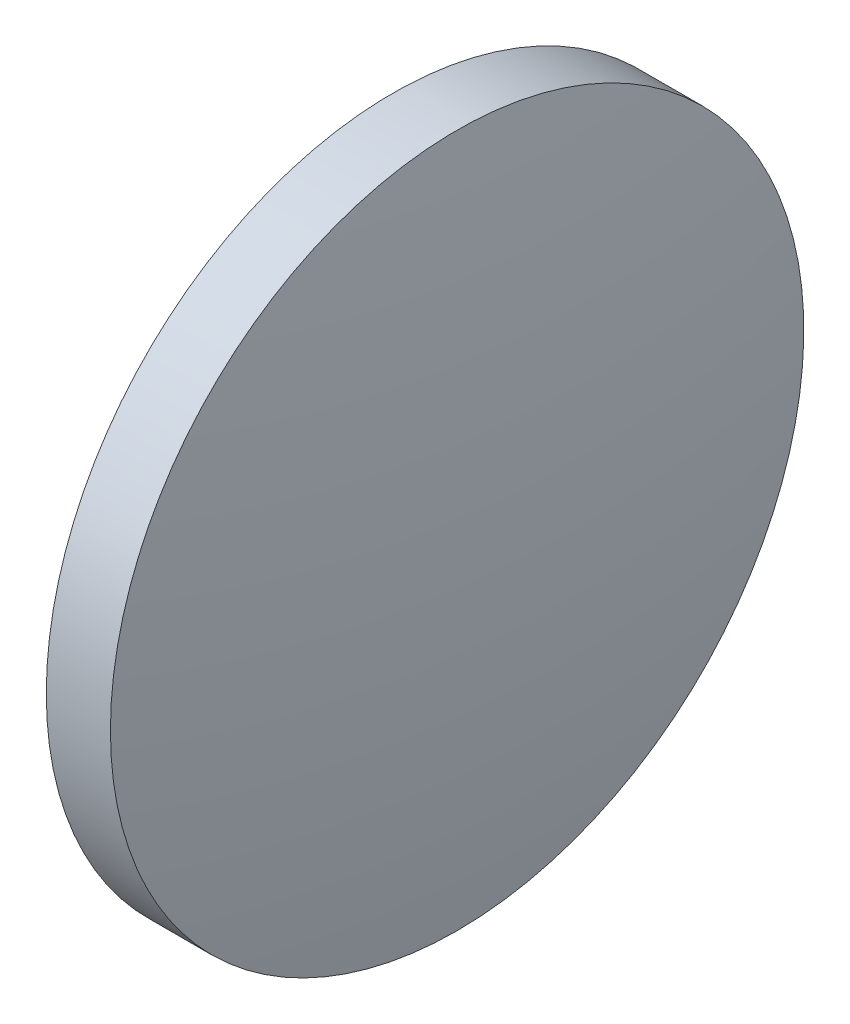
from build123d import *


with BuildPart() as part:
    # 草图1 → 旋转1 (revolve)
    with BuildSketch(Plane.XY, mode=Mode.PRIVATE) as revolve_1_sk:
        with BuildLine():
            Line((430.960614405, 100.311698588), (430.960614405, 108.311698588))
            Line((430.960614405, 108.311698588), (432.440614405, 108.311698588))
            ThreePointArc((432.440614405, 108.311698588), (432.905382359, 104.323693105), (433.060614405, 100.311698588))
            Line((433.060614405, 100.311698588), (430.960614405, 100.311698588))
        make_face()
    revolve(revolve_1_sk.sketch.rotate(Axis((427.235345785, 100.311698588, 0), (1, 0, 0)), 180), axis=Axis((427.235345785, 100.311698588, 0), (1, 0, 0)))  # turned: the seam where the file's is


solid = part.part
